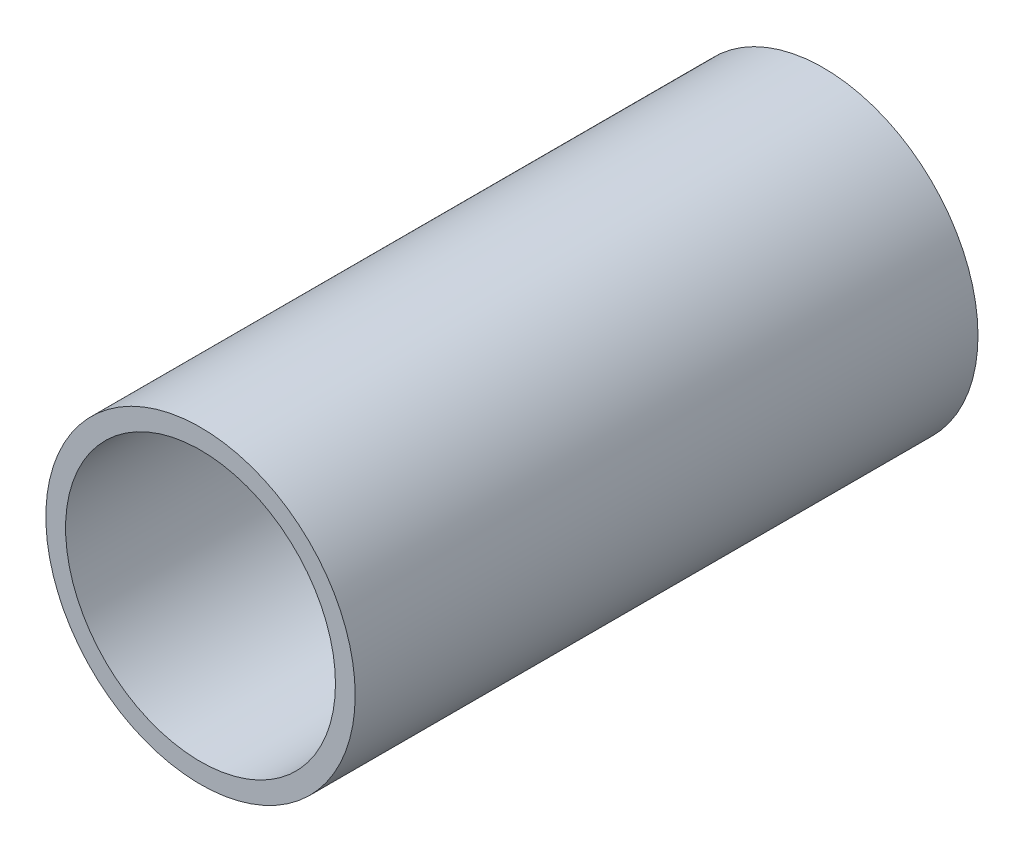
from build123d import *

# Parameters (mm, degrees)
SKETCH1_R           = 18.923
SKETCH1_R_2         = 16.51
BOSS_EXTRUDE1_DEPTH = 76.2


with BuildPart() as part:
    # Sketch1 → Boss-Extrude1 (new body)
    with BuildSketch(Plane.XY):
        Circle(SKETCH1_R)
        Circle(SKETCH1_R_2, mode=Mode.SUBTRACT)
    extrude(amount=BOSS_EXTRUDE1_DEPTH)


solid = part.part
